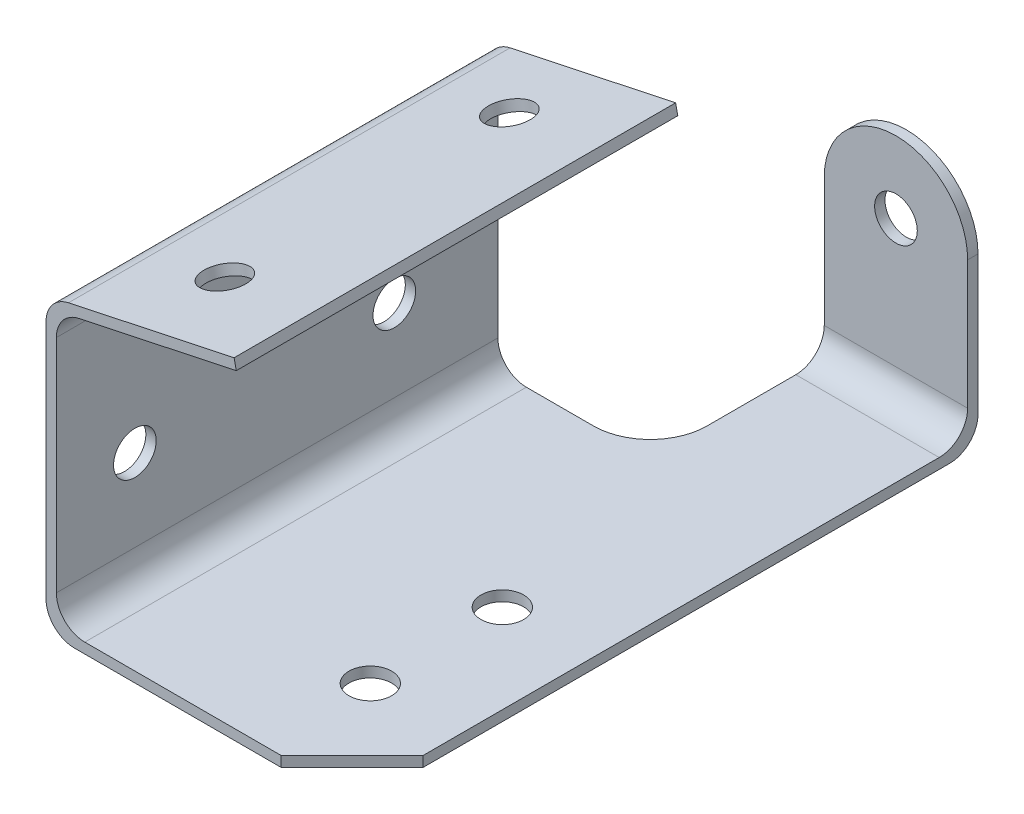
from build123d import *

# Parameters (mm, degrees)
BOSS_EXTRUDE1_DEPTH     = 98.552
BOSS_EXTRUDE2_DEPTH     = 32.004
SKETCH3_R               = 4.7625
CUT_EXTRUDE1_DEPTH      = 3.3114
FILLET1_R               = 12.7
SKETCH4_R               = 4.7625
CUT_EXTRUDE2_DEPTH      = 3.3114
SKETCH5_R               = 4.7625
CUT_EXTRUDE3_DEPTH      = 67.0146
CUT_EXTRUDE3_DEPTH_BACK = 3.3114
CUT_EXTRUDE4_REACH      = 79.809
SKETCH6_R               = 4.7625


with BuildPart() as part:
    # Sketch1 → Boss-Extrude1 (new body)
    with BuildSketch(Plane.XY):
        with BuildLine():
            Line((6.35, 0), (68.326, 0))
            Line((68.326, 0), (68.326, 2.3114))
            Line((68.326, 2.3114), (8.6614, 2.3114))
            ThreePointArc((8.6614, 2.3114), (4.171271939, 4.171271939), (2.3114, 8.6614))
            Line((2.3114, 8.6614), (2.3114, 58.010136575))
            ThreePointArc((2.3114, 58.010136575), (3.726523145, 62.006321058), (7.341160763, 64.22137384))
            Line((7.341160763, 64.22137384), (42.468530991, 71.687926876))
            Line((42.468530991, 71.687926876), (41.987963909, 73.94881724))
            Line((41.987963909, 73.94881724), (5.029760763, 66.093108654))
            ThreePointArc((5.029760763, 66.093108654), (1.415123145, 63.878055872), (0, 59.881871389))
            Line((0, 59.881871389), (0, 6.35))
            ThreePointArc((0, 6.35), (1.859871939, 1.859871939), (6.35, 0))
        make_face()
    extrude(amount=-BOSS_EXTRUDE1_DEPTH)

    # Sketch2 → Boss-Extrude2 (add)
    with BuildSketch(Plane(origin=(68.326, 0, 0), x_dir=(0, 0, -1), z_dir=(1, 0, 0))):
        with BuildLine():
            Line((98.552, 0), (133.35, 0))
            ThreePointArc((133.35, 0), (137.840128061, 1.859871939), (139.7, 6.35))
            Line((139.7, 6.35), (139.7, 53.34))
            Line((139.7, 53.34), (137.3886, 53.34))
            Line((137.3886, 53.34), (137.3886, 8.6614))
            ThreePointArc((137.3886, 8.6614), (135.528728061, 4.171271939), (131.0386, 2.3114))
            Line((131.0386, 2.3114), (98.552, 2.3114))
            Line((98.552, 2.3114), (98.552, 0))
        make_face()
    extrude(amount=-BOSS_EXTRUDE2_DEPTH)

    # Sketch3 → Cut-Extrude1 (cut, through all)
    with BuildSketch(Plane.XY.offset(-137.3886)):
        with BuildLine():
            Line((36.322, 53.34), (36.322, 37.338))
            ThreePointArc((36.322, 37.338), (41.008877287, 48.653122713), (52.324, 53.34))
            Line((52.324, 53.34), (36.322, 53.34))
        make_face()
        with BuildLine():
            ThreePointArc((52.324, 53.34), (63.639122713, 48.653122713), (68.326, 37.338))
            Line((68.326, 37.338), (68.326, 53.34))
            Line((68.326, 53.34), (52.324, 53.34))
        make_face()
        with Locations((52.324, 37.338)):
            Circle(SKETCH3_R)
    extrude(amount=-CUT_EXTRUDE1_DEPTH, mode=Mode.SUBTRACT)

    # Fillet1
    fillet1_edges = [part.edges().sort_by_distance(p)[0] for p in [
        (36.322, 1.1557, -98.552),
    ]]
    fillet(fillet1_edges, radius=FILLET1_R)

    # Sketch4 → Cut-Extrude2 (cut, through all)
    with BuildSketch(Plane(origin=(0, 2.3114, 0), x_dir=(1, 0, 0), z_dir=(0, 1, 0))):
        with Locations((48.514, 23.876)):
            Circle(SKETCH4_R)
        with Locations((48.514, 53.34)):
            Circle(SKETCH4_R)
        Polygon((52.451, 0), (68.326, 15.875), (68.326, 0), align=None)
    extrude(amount=-CUT_EXTRUDE2_DEPTH, mode=Mode.SUBTRACT)

    # Sketch5 → Cut-Extrude3 (cut, two sides)
    with BuildSketch(Plane(origin=(2.3114, 0, 0), x_dir=(0, 0, -1), z_dir=(1, 0, 0))) as cut_extrude3_sk:
        with Locations((17.526, 26.9494)):
            Circle(SKETCH5_R)
        with Locations((75.438, 26.9494)):
            Circle(SKETCH5_R)
        with Locations((17.526, 56.4134)):
            Circle(SKETCH5_R)
        with Locations((75.438, 56.4134)):
            Circle(SKETCH5_R)
    extrude(amount=CUT_EXTRUDE3_DEPTH, mode=Mode.SUBTRACT)
    extrude(cut_extrude3_sk.sketch, amount=-CUT_EXTRUDE3_DEPTH_BACK, mode=Mode.SUBTRACT)

    # Sketch6 → Cut-Extrude4 (cut, up to next)
    with BuildSketch(Plane(origin=(-13.22382174, 62.213189919, 0), x_dir=(0.978147601, 0.207911691, 0), z_dir=(-0.207911691, 0.978147601, 0)), mode=Mode.PRIVATE) as cut_extrude4_sk1:
        with Locations((34.855249784, 82.55)):
            Circle(SKETCH6_R)
    cut_extrude4_tool1 = extrude(cut_extrude4_sk1.sketch, amount=-CUT_EXTRUDE4_REACH, mode=Mode.PRIVATE) & part.part
    add(cut_extrude4_tool1.solids().sort_by_distance((20.869757, 69.460004, -82.55))[0], mode=Mode.SUBTRACT)
    # Sketch6 → Cut-Extrude4 (cut, up to next)
    with BuildSketch(Plane(origin=(-13.22382174, 62.213189919, 0), x_dir=(0.978147601, 0.207911691, 0), z_dir=(-0.207911691, 0.978147601, 0)), mode=Mode.PRIVATE) as cut_extrude4_sk2:
        with Locations((34.855249784, 19.05)):
            Circle(SKETCH6_R)
    cut_extrude4_tool2 = extrude(cut_extrude4_sk2.sketch, amount=-CUT_EXTRUDE4_REACH, mode=Mode.PRIVATE) & part.part
    add(cut_extrude4_tool2.solids().sort_by_distance((20.869757, 69.460004, -19.05))[0], mode=Mode.SUBTRACT)


solid = part.part
